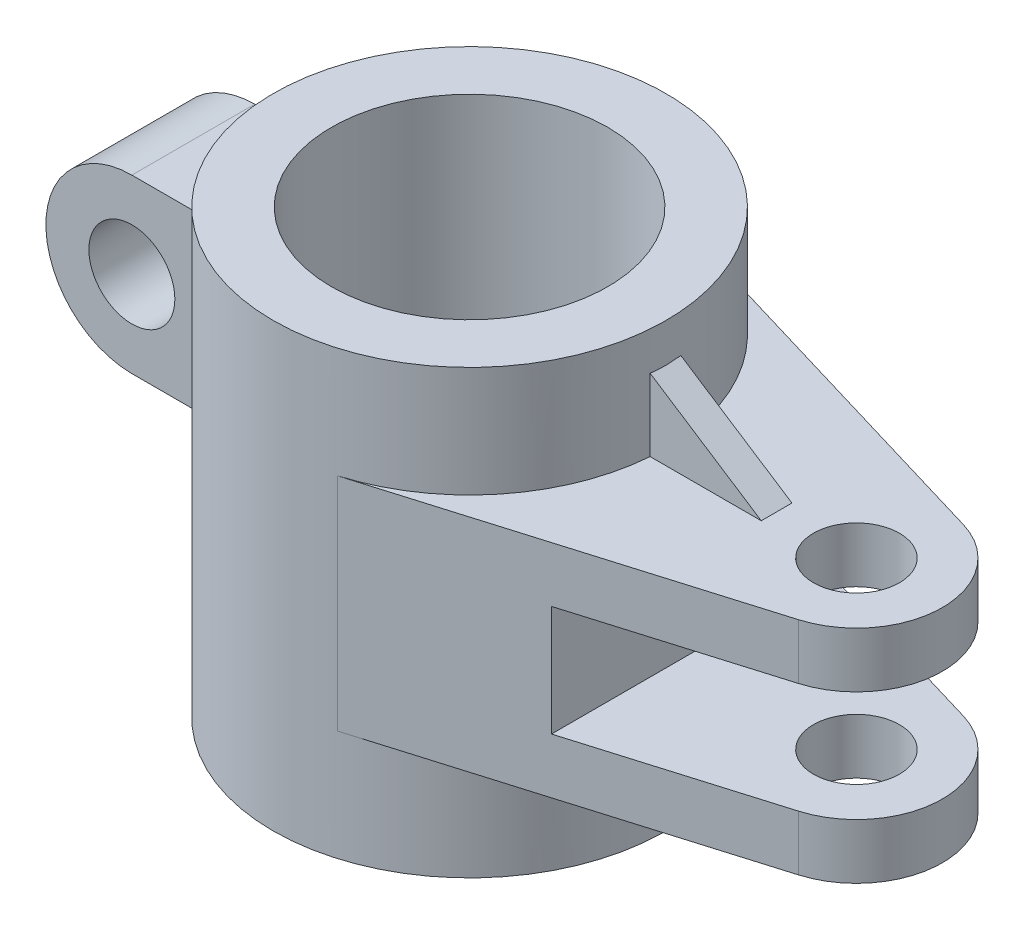
from build123d import *

# Parameters (mm, degrees)
SKETCH_1_R               = 32
SKETCH_1_R_2             = 22.5
EXTRUDE_1_DEPTH          = 72
SKETCH_2_R               = 7
EXTRUDE_2_DEPTH          = 36
CUT_EXTRUDE_1_DEPTH      = 9
EXTRUDE_3_DEPTH          = 14
SKETCH_5_R               = 7
CUT_EXTRUDE_2_DEPTH      = 33
CUT_EXTRUDE_2_DEPTH_BACK = 33
CUT_EXTRUDE_3_DEPTH      = 23
CUT_EXTRUDE_3_DEPTH_BACK = 43
EXTRUDE_4_DEPTH          = 2.5


with BuildPart() as part:
    # 草图1 → 凸台-拉伸1 (new body)
    with BuildSketch(Plane(origin=(0, 0, 0), x_dir=(1, 0, 0), z_dir=(0, 1, 0))):
        Circle(SKETCH_1_R)
        Circle(SKETCH_1_R_2, mode=Mode.SUBTRACT)
    extrude(amount=EXTRUDE_1_DEPTH)

    # 草图2 → 凸台-拉伸2 (add)
    with BuildSketch(Plane(origin=(0, 18, 0), x_dir=(1, 0, 0), z_dir=(0, 1, 0))):
        with BuildLine():
            Line((9.142857143, 30.66607512), (67, 13.416407865))
            ThreePointArc((67, 13.416407865), (77, 0), (67, -13.416407865))
            Line((67, -13.416407865), (9.142857143, -30.66607512))
            ThreePointArc((9.142857143, -30.66607512), (32, 0), (9.142857143, 30.66607512))
        make_face()
        with Locations((63, 0)):
            Circle(SKETCH_2_R, mode=Mode.SUBTRACT)
    extrude(amount=EXTRUDE_2_DEPTH)

    # 草图3 → 切除-拉伸1 (cut, symmetric)
    with BuildSketch(Plane(origin=(0, 36, 0), x_dir=(1, 0, 0), z_dir=(0, 1, 0))):
        with BuildLine():
            Line((36, 22.658822172), (36, -22.658822172))
            Line((36, -22.658822172), (67, -13.416407865))
            ThreePointArc((67, -13.416407865), (77, 0), (67, 13.416407865))
            Line((67, 13.416407865), (36, 22.658822172))
        make_face()
    extrude(amount=CUT_EXTRUDE_1_DEPTH, both=True, mode=Mode.SUBTRACT)

    # 草图4 → 凸台-拉伸3 (add, symmetric)
    with BuildSketch(Plane(origin=(0, 45, 0), x_dir=(1, 0, 0), z_dir=(0, 1, 0))):
        with BuildLine():
            Line((-30.330505487, 10), (-45, 10))
            Line((-45, 10), (-59, 10))
            Line((-59, 10), (-59, -10))
            Line((-59, -10), (-45, -10))
            Line((-45, -10), (-30.330505487, -10))
            ThreePointArc((-30.330505487, -10), (-31.936492655, 0), (-30.330505487, 10))
        make_face()
    extrude(amount=EXTRUDE_3_DEPTH, both=True)

    # 草图5 → 切除-拉伸2 (cut, two sides)
    with BuildSketch(Plane.XY) as cut_extrude_2_sk:
        with Locations((-45, 45)):
            Circle(SKETCH_5_R)
    extrude(amount=CUT_EXTRUDE_2_DEPTH, mode=Mode.SUBTRACT)
    extrude(cut_extrude_2_sk.sketch, amount=-CUT_EXTRUDE_2_DEPTH_BACK, mode=Mode.SUBTRACT)

    # 草图6 → 切除-拉伸3 (cut, two sides)
    with BuildSketch(Plane.XY.offset(10)) as cut_extrude_3_sk:
        with BuildLine():
            Line((-45, 59), (-45, 73.390549991))
            Line((-45, 73.390549991), (-74.161740497, 70.167226716))
            Line((-74.161740497, 70.167226716), (-67.715093947, 21.172712935))
            Line((-67.715093947, 21.172712935), (-45.42483437, 31.00644735))
            ThreePointArc((-45.42483437, 31.00644735), (-58.99838807, 45.212441645), (-45, 59))
        make_face()
    extrude(amount=CUT_EXTRUDE_3_DEPTH, mode=Mode.SUBTRACT)
    extrude(cut_extrude_3_sk.sketch, amount=-CUT_EXTRUDE_3_DEPTH_BACK, mode=Mode.SUBTRACT)

    # 草图7 → 凸台-拉伸4 (add, symmetric)
    with BuildSketch(Plane.XY):
        Polygon((50, 54), (28.987302247, 67.645805474), (28.987302247, 54), align=None)
    extrude(amount=EXTRUDE_4_DEPTH, both=True)


solid = part.part
